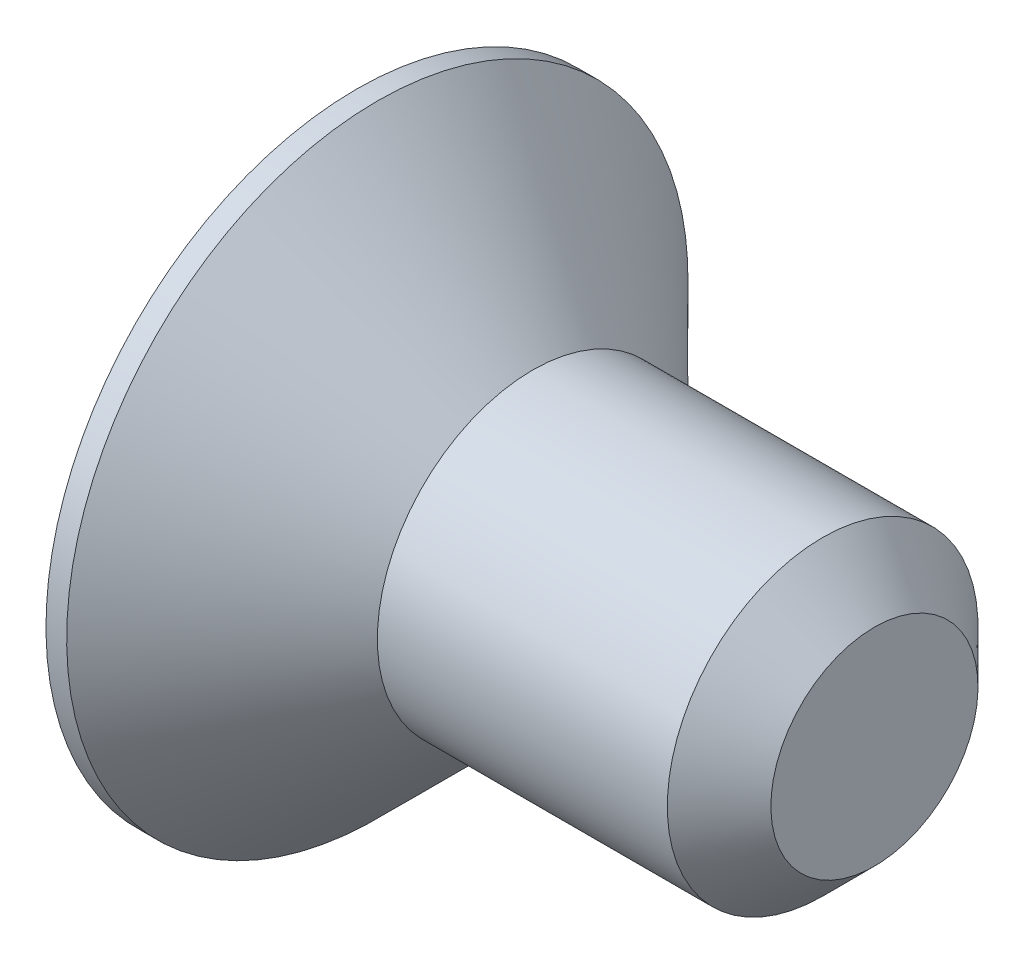
from build123d import *

# Parameters (mm, degrees)
CHANFREIN1_SIZE         = 0.5
ENL_V_MAT_EXTRU_1_DEPTH = 1.2


with BuildPart() as part:
    # Esquisse1 → Révolution1 (revolve)
    with BuildSketch(Plane.XY):
        Polygon((0, 0), (0, 3), (0.2, 3), (1.7, 1.5), (5, 1.5), (5, 0), align=None)
    revolve(axis=Axis((5, 0, 0), (-1, 0, 0)))

    # Chanfrein1
    chanfrein1_edges = [part.edges().sort_by_distance(p)[0] for p in [
        (5, -1.5, 0),
    ]]
    chamfer(chanfrein1_edges, length=CHANFREIN1_SIZE)

    # Esquisse2 → Enlèv. mat.-Extru.1 (cut)
    with BuildSketch(Plane.ZY):
        Polygon((0, 1.154700538), (-1, 0.577350269), (-1, -0.577350269), (0, -1.154700538), (1, -0.577350269), (1, 0.577350269), align=None)
    extrude(amount=-ENL_V_MAT_EXTRU_1_DEPTH, mode=Mode.SUBTRACT)


solid = part.part
